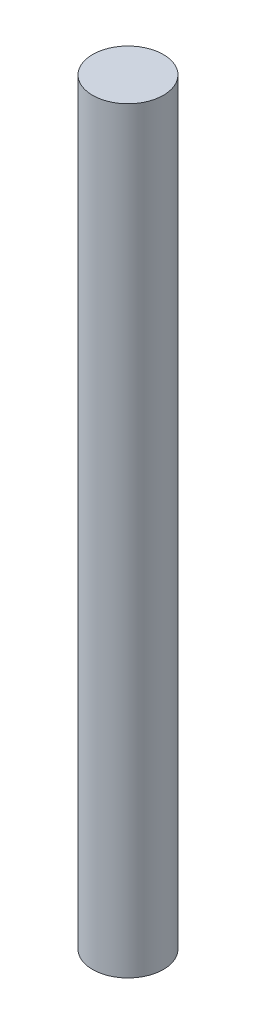
from build123d import *

# Parameters (mm, degrees)
SKETCH1_R           = 2.5
BOSS_EXTRUDE1_DEPTH = 53.5


with BuildPart() as part:
    # Sketch1 → Boss-Extrude1 (new body)
    with BuildSketch(Plane(origin=(0, 0, 0), x_dir=(1, 0, 0), z_dir=(0, 1, 0))):
        Circle(SKETCH1_R)
    extrude(amount=BOSS_EXTRUDE1_DEPTH)


solid = part.part
